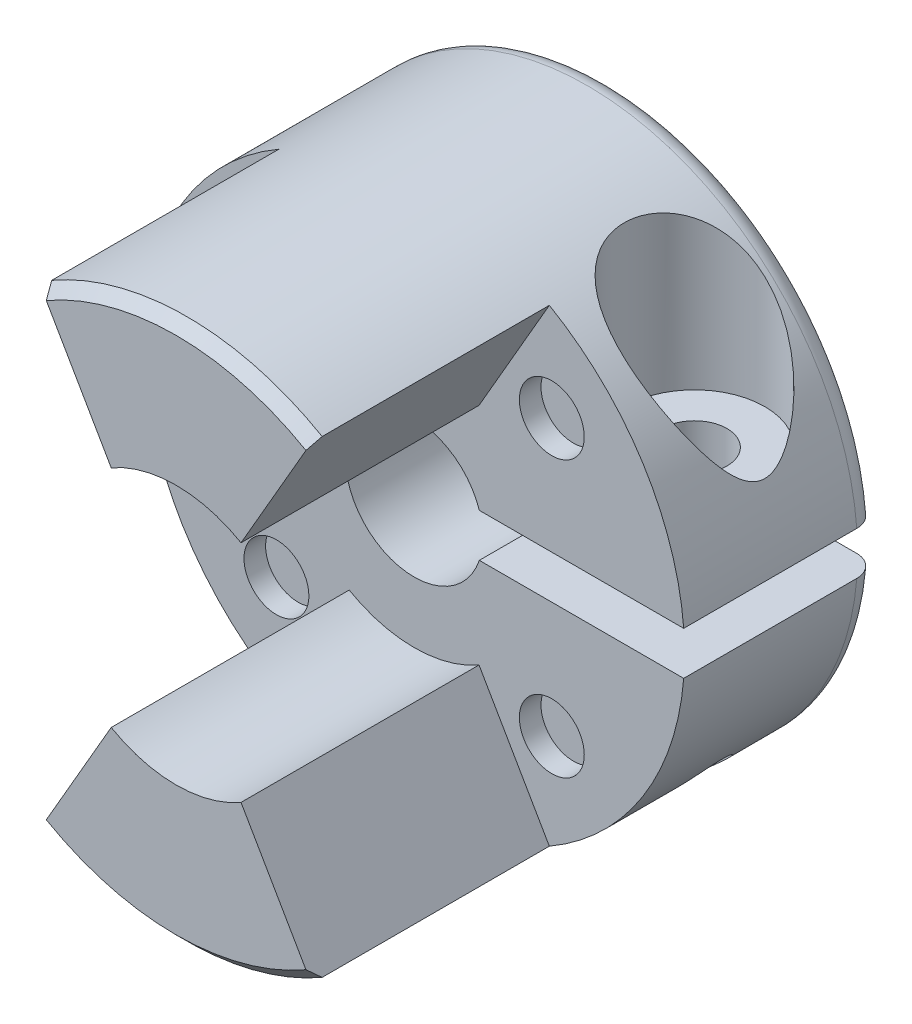
from build123d import *

# Parameters (mm, degrees)
ESBO_O1_R                 = 12.5
RESSALTO_EXTRUS_O1_DEPTH  = 20
CORTE_EXTRUS_O3_DEPTH     = 11
ESBO_O3_R                 = 3.175
CORTE_EXTRUS_O4_DEPTH     = 21
ESBO_O6_W                 = 12
ESBO_O6_H                 = 2
CORTE_EXTRUS_O5_DEPTH     = 10
CORTE_EXTRUS_O6_START     = -3
ESBO_O7_R                 = 3.25
CORTE_EXTRUS_O6_DEPTH     = 9.5
FURO_ROSCADO_DE_M3X0_51_D = 2.5
FILETE1_R                 = 1
ESBO_O10_R                = 1.5
CORTE_EXTRUS_O7_DEPTH     = 1
CHANFRO1_SIZE             = 0.5
CORTE_EXTRUS_O8_REACH     = 18.5
ESBO_O11_R                = 1.5
ESBO_O12_R                = 6
CORTE_EXTRUS_O9_DEPTH     = 11
PADR_OCIRCULAR1_COUNT     = 4
CHANFRO2_SIZE             = 0.5


with BuildPart() as part:
    # Esboço1 → Ressalto-extrusão1 (new body)
    with BuildSketch(Plane.XY):
        Circle(ESBO_O1_R)
    extrude(amount=RESSALTO_EXTRUS_O1_DEPTH)

    # Esboço2 → Corte-extrusão3 (cut)
    with BuildSketch(Plane.XY.offset(20)):
        with BuildLine():
            Line((0, 0), (6.25, 10.825317547))
            ThreePointArc((6.25, 10.825317547), (12.5, 0), (6.25, -10.825317547))
            Line((6.25, -10.825317547), (0, 0))
        make_face()
    corte_extrus_o3 = extrude(amount=-CORTE_EXTRUS_O3_DEPTH, mode=Mode.SUBTRACT)

    # Esboço3 → Corte-extrusão4 (cut, through all)
    with BuildSketch(Plane(origin=(0, 0, 0), x_dir=(-1, 0, 0), z_dir=(0, 0, -1))):
        Circle(ESBO_O3_R)
    extrude(amount=-CORTE_EXTRUS_O4_DEPTH, mode=Mode.SUBTRACT)

    # Espelhar1: Corte-extrusão3 across plane
    add(corte_extrus_o3.mirror(Plane(origin=(0, 0, 0), x_dir=(0, 0, 1), z_dir=(1, 0, 0))), mode=Mode.SUBTRACT)

    # Esboço6 → Corte-extrusão5 (cut, through all)
    with BuildSketch(Plane.XY.offset(9)):
        with Locations((7, 0)):
            Rectangle(ESBO_O6_W, ESBO_O6_H)
    extrude(amount=-CORTE_EXTRUS_O5_DEPTH, mode=Mode.SUBTRACT)

    # Esboço7 → Corte-extrusão6 (cut, through all)
    with BuildSketch(Plane.XZ.offset(-1).offset(CORTE_EXTRUS_O6_START)):
        with Locations((8.459935794, 4.5)):
            Circle(ESBO_O7_R)
    extrude(amount=-CORTE_EXTRUS_O6_DEPTH, mode=Mode.SUBTRACT)

    # Furo roscado de M3x0.51 (through all)
    with Locations(Plane(origin=(0, 4, 0), x_dir=(1, 0, 0), z_dir=(0, 1, 0))):
        with Locations((8.459935794, -4.5)):
            Hole(FURO_ROSCADO_DE_M3X0_51_D / 2)

    # Filete1
    filete1_edges = [part.edges().sort_by_distance(p)[0] for p in [
        (-12.5, 0, 0),
    ]]
    fillet(filete1_edges, radius=FILETE1_R)

    # Esboço10 → Corte-extrusão7 (cut)
    with BuildSketch(Plane.XY.offset(9)):
        with Locations((6.363961031, -6.363961031)):
            Circle(ESBO_O10_R)
    corte_extrus_o7 = extrude(amount=-CORTE_EXTRUS_O7_DEPTH, mode=Mode.SUBTRACT)

    # Chanfro1
    chanfro1_edges = [part.edges().sort_by_distance(p)[0] for p in [
        (0, -12.5, 20),
        (0, 12.5, 20),
    ]]
    chamfer(chanfro1_edges, length=CHANFRO1_SIZE)

    # Esboço11 → Corte-extrusão8 (cut, up to next)
    with BuildSketch(Plane(origin=(0, 4, 0), x_dir=(1, 0, 0), z_dir=(0, 1, 0)), mode=Mode.PRIVATE) as corte_extrus_o8_sk1:
        with Locations((8.459935794, -4.5)):
            Circle(ESBO_O11_R)
    corte_extrus_o8_tool1 = extrude(corte_extrus_o8_sk1.sketch, amount=-CORTE_EXTRUS_O8_REACH, mode=Mode.PRIVATE) & part.part
    add(corte_extrus_o8_tool1.solids().sort_by_distance((8.459936, 4, 4.5))[0], mode=Mode.SUBTRACT)

    # Esboço12 → Corte-extrusão9 (cut)
    with BuildSketch(Plane.XY.offset(20)):
        Circle(ESBO_O12_R)
    extrude(amount=-CORTE_EXTRUS_O9_DEPTH, mode=Mode.SUBTRACT)

    # PadrãoCircular1: Corte-extrusão7 ×4 about axis
    padr_ocircular1_axis = Axis((0, 0, 0), (0, 0, 1))
    for i in range(1, PADR_OCIRCULAR1_COUNT):
        add(corte_extrus_o7.rotate(padr_ocircular1_axis, i * 360 / PADR_OCIRCULAR1_COUNT), mode=Mode.SUBTRACT)

    # Chanfro2
    chanfro2_edges = [part.edges().sort_by_distance(p)[0] for p in [
        (-3.175, 0, 0),
    ]]
    chamfer(chanfro2_edges, length=CHANFRO2_SIZE)


solid = part.part
